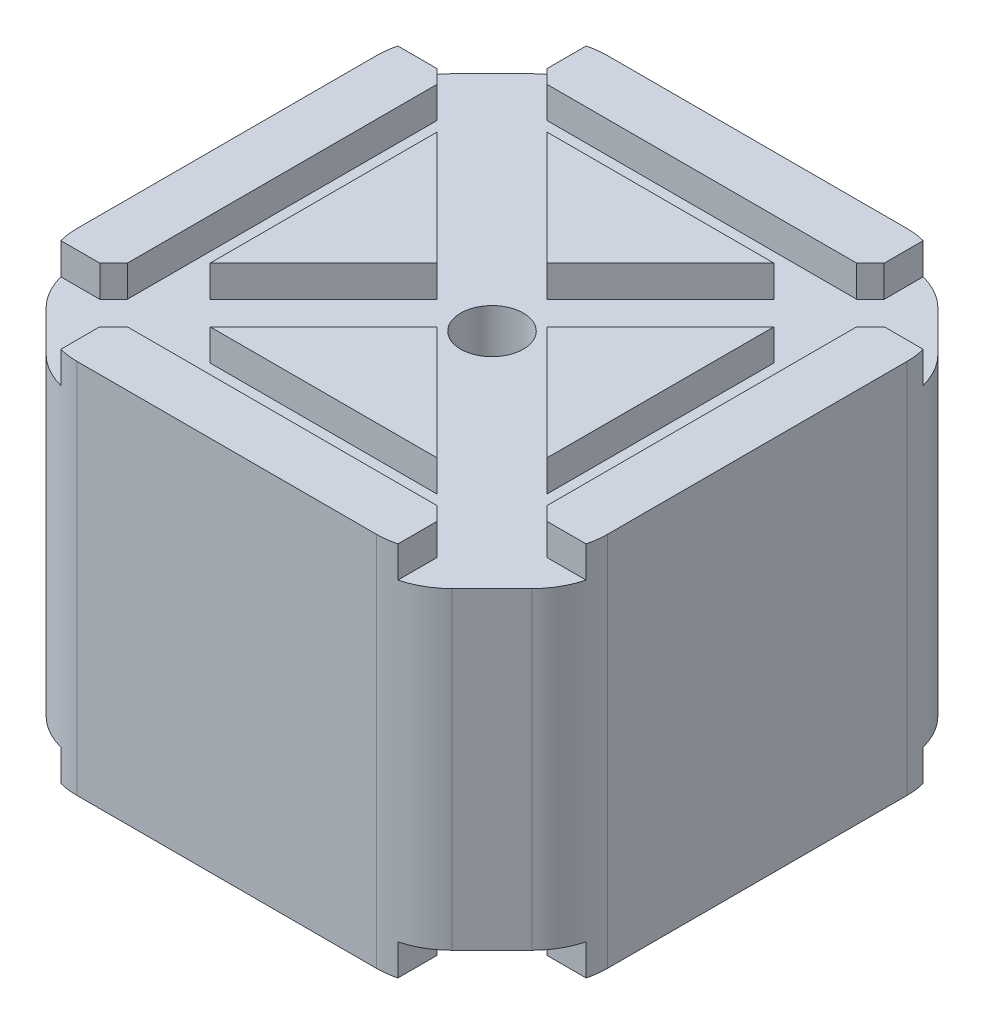
from build123d import *

# Parameters (mm, degrees)
BOSS_EXTRUDE1_DEPTH = 15
SKETCH18_W          = 3.3
SKETCH18_H          = 2.5
CUT_EXTRUDE10_DEPTH = 43.3
SKETCH19_W          = 3.3
SKETCH19_H          = 2.5
CUT_EXTRUDE11_DEPTH = 43.3
SKETCH20_W          = 6.221233688
SKETCH20_H          = 2.5
CUT_EXTRUDE12_DEPTH = 57.710616844
SKETCH21_W          = 6.221233688
SKETCH21_H          = 2.5
CUT_EXTRUDE13_DEPTH = 57.710616844
SKETCH22_R          = 2.5
CUT_EXTRUDE14_DEPTH = 13.5
CUT_EXTRUDE15_DEPTH = 28.5
FILLET8_R           = 6


with BuildPart() as part:
    # Sketch1 → Boss-Extrude1 (new body)
    with BuildSketch(Plane(origin=(0, 0, 0), x_dir=(1, 0, 0), z_dir=(0, 1, 0))):
        Polygon((-21.15, 16.750923472), (-16.750923472, 21.15), (16.750923472, 21.15), (21.15, 16.750923472), (21.15, -16.750923472), (16.750923472, -21.15), (-16.750923472, -21.15), (-21.15, -16.750923472), align=None)
    boss_extrude1 = extrude(amount=BOSS_EXTRUDE1_DEPTH)

    # Sketch18 → Cut-Extrude10 (cut, through all)
    with BuildSketch(Plane.XY.offset(21.15)):
        with Locations((15.100923472, 13.75)):
            Rectangle(SKETCH18_W, SKETCH18_H)
        with Locations((-15.100923472, 13.75)):
            Rectangle(SKETCH18_W, SKETCH18_H)
    cut_extrude10 = extrude(amount=-CUT_EXTRUDE10_DEPTH, mode=Mode.SUBTRACT)

    # Sketch19 → Cut-Extrude11 (cut, through all)
    with BuildSketch(Plane(origin=(21.15, 0, 0), x_dir=(0, 0, -1), z_dir=(1, 0, 0))):
        with Locations((-15.100923472, 13.75)):
            Rectangle(SKETCH19_W, SKETCH19_H)
        with Locations((15.100923472, 13.75)):
            Rectangle(SKETCH19_W, SKETCH19_H)
    cut_extrude11 = extrude(amount=-CUT_EXTRUDE11_DEPTH, mode=Mode.SUBTRACT)

    # Sketch20 → Cut-Extrude12 (cut, through all)
    with BuildSketch(Plane(origin=(18.950461736, 0, 18.950461736), x_dir=(0.707106781, 0, -0.707106781), z_dir=(0.707106781, 0, 0.707106781))):
        with Locations((0, 13.75)):
            Rectangle(SKETCH20_W, SKETCH20_H)
    cut_extrude12 = extrude(amount=-CUT_EXTRUDE12_DEPTH, mode=Mode.SUBTRACT)

    # Sketch21 → Cut-Extrude13 (cut, through all)
    with BuildSketch(Plane(origin=(-18.950461736, 0, 18.950461736), x_dir=(0.707106781, 0, 0.707106781), z_dir=(-0.707106781, 0, 0.707106781))):
        with Locations((0, 13.75)):
            Rectangle(SKETCH21_W, SKETCH21_H)
    cut_extrude13 = extrude(amount=-CUT_EXTRUDE13_DEPTH, mode=Mode.SUBTRACT)

    # Sketch22 → Cut-Extrude14 (cut, through all)
    with BuildSketch(Plane(origin=(0, 12.5, 0), x_dir=(1, 0, 0), z_dir=(0, 1, 0))):
        Circle(SKETCH22_R)
    cut_extrude14 = extrude(amount=-CUT_EXTRUDE14_DEPTH, mode=Mode.SUBTRACT)

    # Mirror1: Boss-Extrude1, Cut-Extrude10, Cut-Extrude11, Cut-Extrude12, Cut-Extrude13, Cut-Extrude14 across plane
    add(boss_extrude1.mirror(Plane(origin=(0, 0, 0), x_dir=(0, 0, 1), z_dir=(0, -1, 0))))
    add(cut_extrude10.mirror(Plane(origin=(0, 0, 0), x_dir=(0, 0, 1), z_dir=(0, -1, 0))), mode=Mode.SUBTRACT)
    add(cut_extrude11.mirror(Plane(origin=(0, 0, 0), x_dir=(0, 0, 1), z_dir=(0, -1, 0))), mode=Mode.SUBTRACT)
    add(cut_extrude12.mirror(Plane(origin=(0, 0, 0), x_dir=(0, 0, 1), z_dir=(0, -1, 0))), mode=Mode.SUBTRACT)
    add(cut_extrude13.mirror(Plane(origin=(0, 0, 0), x_dir=(0, 0, 1), z_dir=(0, -1, 0))), mode=Mode.SUBTRACT)
    add(cut_extrude14.mirror(Plane(origin=(0, 0, 0), x_dir=(0, 0, 1), z_dir=(0, -1, 0))), mode=Mode.SUBTRACT)

    # Sketch23 → Cut-Extrude15 (cut, through all)
    with BuildSketch(Plane(origin=(0, 12.5, 0), x_dir=(1, 0, 0), z_dir=(0, 1, 0))):
        Polygon((-21.15, -14.432485579), (-14.432485579, -21.15), (-16.750923472, -21.15), (-21.15, -16.750923472), align=None)
        Polygon((-21.15, 14.432485579), (-14.432485579, 21.15), (-16.750923472, 21.15), (-21.15, 16.750923472), align=None)
        Polygon((14.432485579, 21.15), (21.15, 14.432485579), (21.15, 16.750923472), (16.750923472, 21.15), align=None)
        Polygon((14.432485579, -21.15), (21.15, -14.432485579), (21.15, -16.750923472), (16.750923472, -21.15), align=None)
    extrude(amount=-CUT_EXTRUDE15_DEPTH, mode=Mode.SUBTRACT)

    # Fillet8
    fillet8_edges = [part.edges().sort_by_distance(p)[0] for p in [
        (14.432485579, 0, -21.15),
        (21.15, 0, -14.432485579),
        (-21.15, 0, -14.432485579),
        (-14.432485579, 0, -21.15),
        (-14.432485579, 0, 21.15),
        (-21.15, 0, 14.432485579),
        (21.15, 0, 14.432485579),
        (14.432485579, 0, 21.15),
    ]]
    fillet(fillet8_edges, radius=FILLET8_R)


solid = part.part
